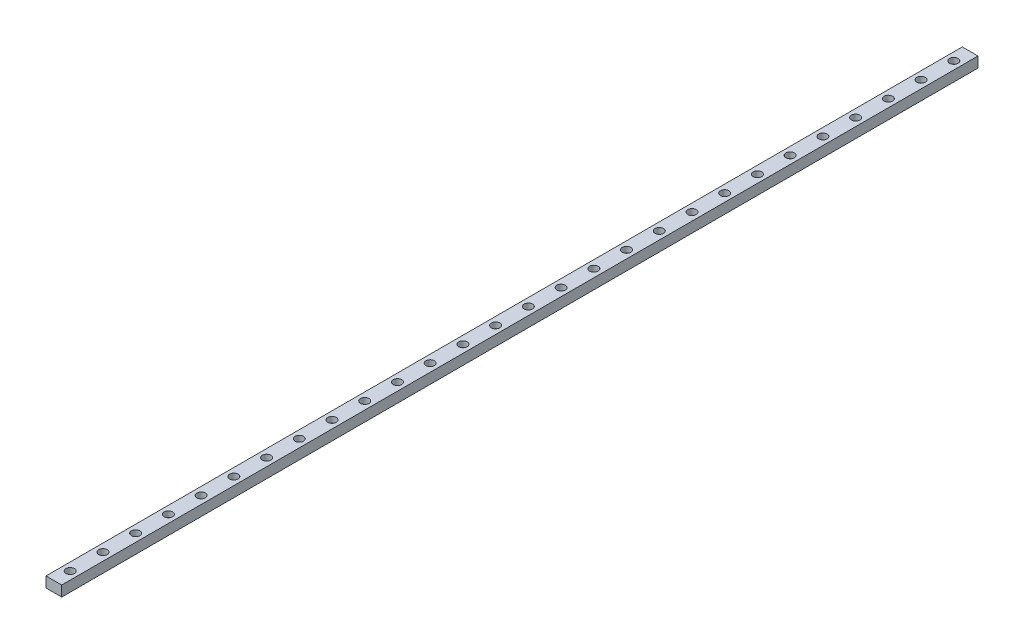
from build123d import *

# Parameters (mm, degrees)
SKETCH1_W                      = 12
SKETCH1_H                      = 8
BOSS_EXTRUDE1_DEPTH            = 700
CBORE_FOR_M3_SHCS1_D           = 3.4
CBORE_FOR_M3_SHCS1_CBORE_D     = 6.5
CBORE_FOR_M3_SHCS1_CBORE_DEPTH = 4.5


with BuildPart() as part:
    # Sketch1 → Boss-Extrude1 (new body)
    with BuildSketch(Plane.XY):
        with Locations((6, 4)):
            Rectangle(SKETCH1_W, SKETCH1_H)
    extrude(amount=BOSS_EXTRUDE1_DEPTH)

    # CBORE for M3 SHCS1 (through all)
    with Locations(Plane(origin=(0, 8, 0), x_dir=(1, 0, 0), z_dir=(0, 1, 0))):
        with Locations((6, -687.5), (6, -662.5), (6, -637.5), (6, -612.5), (6, -587.5), (6, -562.5), (6, -537.5), (6, -512.5), (6, -487.5), (6, -462.5), (6, -437.5), (6, -412.5), (6, -387.5), (6, -362.5), (6, -337.5), (6, -312.5), (6, -287.5), (6, -262.5), (6, -237.5), (6, -212.5), (6, -187.5), (6, -162.5), (6, -137.5), (6, -112.5), (6, -87.5), (6, -62.5), (6, -37.5), (6, -12.5)):
            CounterBoreHole(CBORE_FOR_M3_SHCS1_D / 2, CBORE_FOR_M3_SHCS1_CBORE_D / 2, CBORE_FOR_M3_SHCS1_CBORE_DEPTH)


solid = part.part
